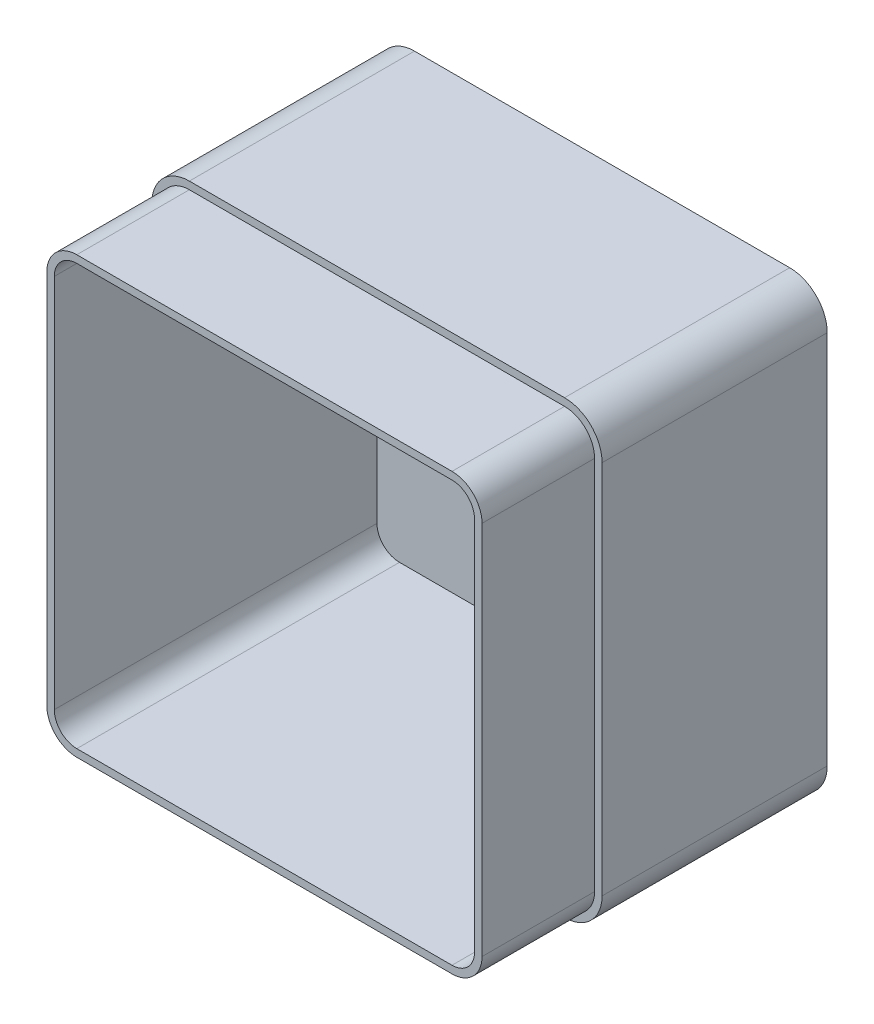
from build123d import *

# Parameters (mm, degrees)
SKICA1_W                 = 120
SKICA1_H                 = 120
VYSUNOUT1_DEPTH          = 90
ZAOBLIT1_R               = 10
ZAOBLIT2_R               = 10
ZAOBLIT3_R               = 10
ZAOBLIT4_R               = 10
SKO_EPINA4_T             = -4
SKICA2_OUTSIDE_W         = 160.418
SKICA2_OUTSIDE_H         = 160.418
ODEBRAT_VYSUNUT_M1_DEPTH = 30


with BuildPart() as part:
    # Skica1 → Vysunout1 (new body)
    with BuildSketch(Plane.XY):
        with Locations((60, 60)):
            Rectangle(SKICA1_W, SKICA1_H)
    extrude(amount=VYSUNOUT1_DEPTH)

    # Zaoblit1
    zaoblit1_edges = [part.edges().sort_by_distance(p)[0] for p in [
        (120, 120, 45),
    ]]
    fillet(zaoblit1_edges, radius=ZAOBLIT1_R)

    # Zaoblit2
    zaoblit2_edges = [part.edges().sort_by_distance(p)[0] for p in [
        (0, 120, 45),
    ]]
    fillet(zaoblit2_edges, radius=ZAOBLIT2_R)

    # Zaoblit3
    zaoblit3_edges = [part.edges().sort_by_distance(p)[0] for p in [
        (0, 0, 45),
    ]]
    fillet(zaoblit3_edges, radius=ZAOBLIT3_R)

    # Zaoblit4
    zaoblit4_edges = [part.edges().sort_by_distance(p)[0] for p in [
        (120, 0, 45),
    ]]
    fillet(zaoblit4_edges, radius=ZAOBLIT4_R)

    # Skořepina4
    sko_epina4_openings = [part.faces().sort_by_distance(p)[0] for p in [
        (60, 60, 90),
    ]]
    offset(amount=SKO_EPINA4_T, openings=sko_epina4_openings, kind=Kind.INTERSECTION)

    # Skica2 outside → Odebrat vysunutím1 (cut)
    with BuildSketch(Plane.XY.offset(90)):
        with Locations((60, 60)):
            Rectangle(SKICA2_OUTSIDE_W, SKICA2_OUTSIDE_H)
        with BuildLine():
            Line((10, 2), (110, 2))
            ThreePointArc((110, 2), (115.656854249, 4.343145751), (118, 10))
            Line((118, 10), (118, 110))
            ThreePointArc((118, 110), (115.656854249, 115.656854249), (110, 118))
            Line((110, 118), (10, 118))
            ThreePointArc((10, 118), (4.343145751, 115.656854249), (2, 110))
            Line((2, 110), (2, 10))
            ThreePointArc((2, 10), (4.343145751, 4.343145751), (10, 2))
        make_face(mode=Mode.SUBTRACT)
    extrude(amount=-ODEBRAT_VYSUNUT_M1_DEPTH, mode=Mode.SUBTRACT)


solid = part.part
